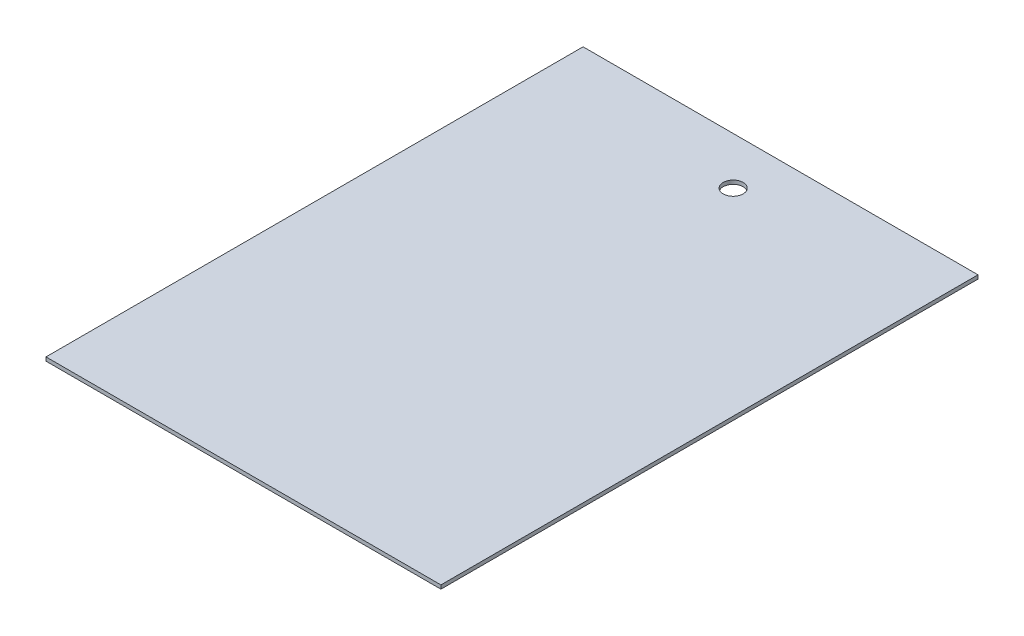
from build123d import *

# Parameters (mm, degrees)
SKETCH1_W           = 317.5
SKETCH1_H           = 431.8
BOSS_EXTRUDE1_DEPTH = 3
SKETCH2_R           = 8
CUT_EXTRUDE1_DEPTH  = 4


with BuildPart() as part:
    # Sketch1 → Boss-Extrude1 (new body)
    with BuildSketch(Plane(origin=(0, 0, 0), x_dir=(1, 0, 0), z_dir=(0, 1, 0))):
        Rectangle(SKETCH1_W, SKETCH1_H)
    extrude(amount=BOSS_EXTRUDE1_DEPTH)

    # Sketch2 → Cut-Extrude1 (cut, through all)
    with BuildSketch(Plane(origin=(0, 3, 0), x_dir=(1, 0, 0), z_dir=(0, 1, 0))):
        with Locations((0, 177.8)):
            Circle(SKETCH2_R)
    extrude(amount=-CUT_EXTRUDE1_DEPTH, mode=Mode.SUBTRACT)


solid = part.part
